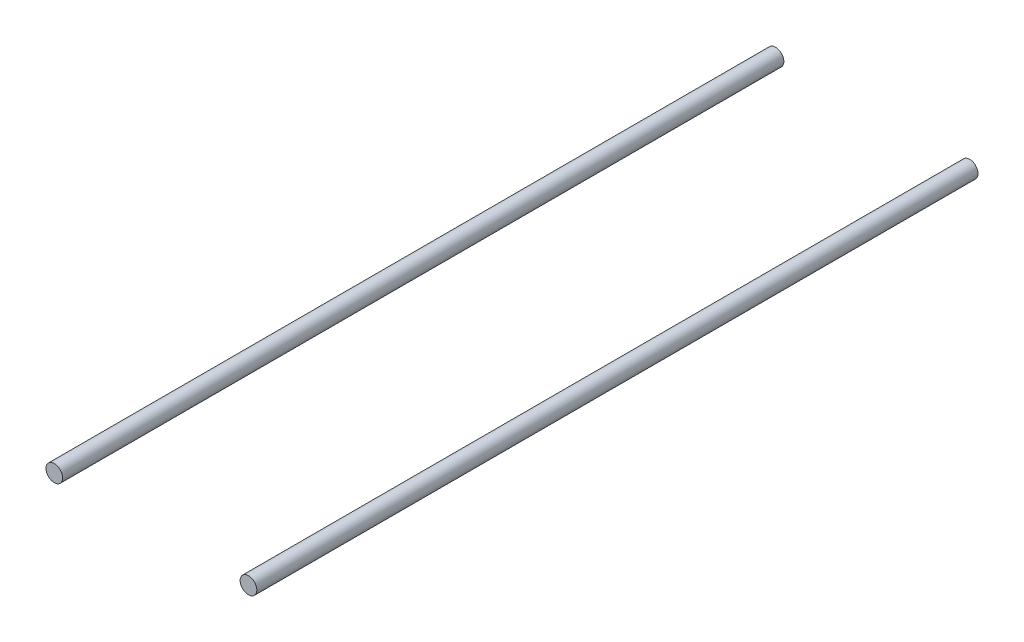
from build123d import *

# Parameters (mm, degrees)
SKIZZE2_R                              = 3
AUFSATZ_LINEAR_AUSTRAGEN1_DEPTH        = 130
AUFSATZ_LINEAR_AUSTRAGEN1_DEPTH_BACK   = 130
AUFSATZ_LINEAR_AUSTRAGEN1_2_DEPTH      = 130
AUFSATZ_LINEAR_AUSTRAGEN1_2_DEPTH_BACK = 130


with BuildPart() as part:
    # Skizze2 → Aufsatz-Linear austragen1 (new body, two sides)
    with BuildSketch(Plane.XY) as aufsatz_linear_austragen1_sk:
        with Locations((70, 670)):
            Circle(SKIZZE2_R)
    extrude(amount=AUFSATZ_LINEAR_AUSTRAGEN1_DEPTH)
    extrude(aufsatz_linear_austragen1_sk.sketch, amount=-AUFSATZ_LINEAR_AUSTRAGEN1_DEPTH_BACK)


with BuildPart() as body_2:
    # Skizze2 → Aufsatz-Linear austragen1 2 (new body, two sides)
    with BuildSketch(Plane.XY) as aufsatz_linear_austragen1_2_sk:
        with Locations((0, 670)):
            Circle(SKIZZE2_R)
    extrude(amount=AUFSATZ_LINEAR_AUSTRAGEN1_2_DEPTH)
    extrude(aufsatz_linear_austragen1_2_sk.sketch, amount=-AUFSATZ_LINEAR_AUSTRAGEN1_2_DEPTH_BACK)


solid = Compound([part.part, body_2.part])
